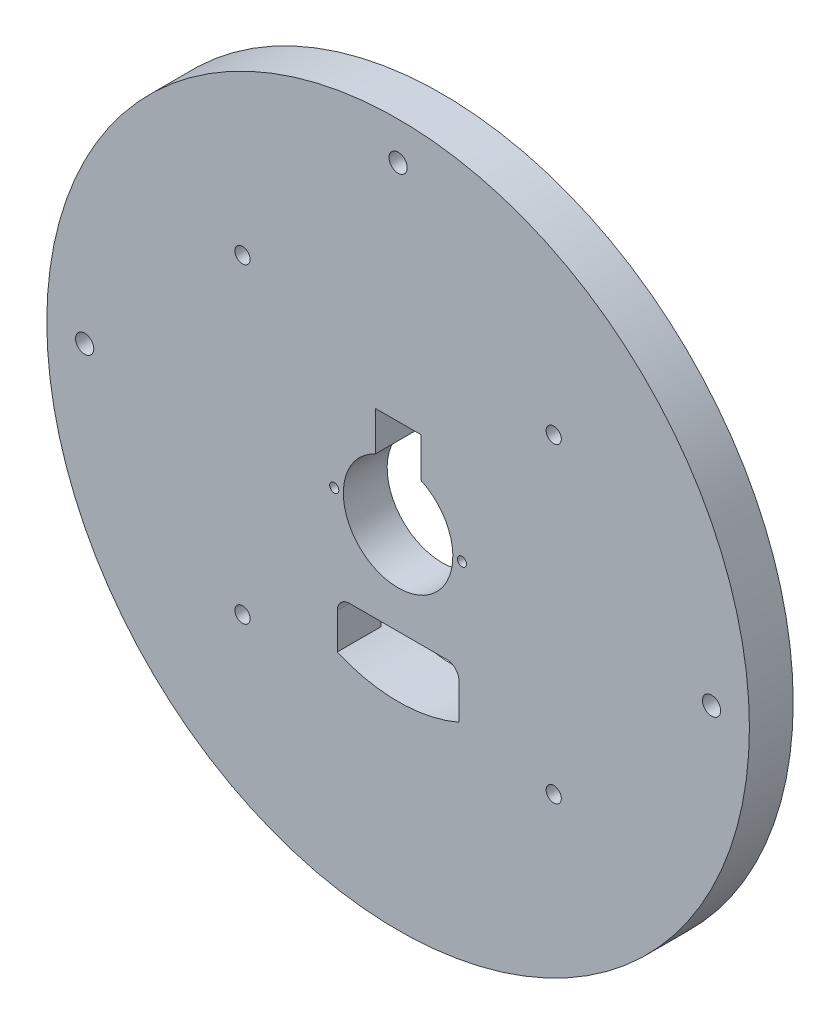
from build123d import *

# Parameters (mm, degrees)
BOSS_EXTRUDE1_DEPTH     = 14.4
MOTORMOUNTLOCKRINGS_R   = 90.6
MOTORMOUNTLOCKRINGS_R_2 = 50.4
BOSS_EXTRUDE2_DEPTH     = 5
CUT_EXTRUDE1_DEPTH      = 18.4
CUT_EXTRUDE2_DEPTH      = 15.4
F_5_0MM_DOWEL_HOLE1_D   = 5
F_3_0MM_DOWEL_HOLE3_D   = 3
F_6_0MM_DOWEL_HOLE4_D   = 6


with BuildPart() as part:
    # motorMount → Boss-Extrude1 (new body)
    with BuildSketch(Plane.XY):
        with BuildLine():
            ThreePointArc((115.302334192, 6.754385965), (0, 115.5), (-115.302334192, 6.754385965))
            ThreePointArc((-115.302334192, 6.754385965), (-115.5, 0), (-115.302334192, -6.754385965))
            ThreePointArc((-115.302334192, -6.754385965), (0, -115.5), (115.302334192, -6.754385965))
            ThreePointArc((115.302334192, -6.754385965), (115.5, 0), (115.302334192, 6.754385965))
        make_face()
    extrude(amount=BOSS_EXTRUDE1_DEPTH)

    # motorMountLockRings → Boss-Extrude2 (add)
    with BuildSketch(Plane(origin=(0, 0, 0), x_dir=(-1, 0, 0), z_dir=(0, 0, -1))):
        Circle(MOTORMOUNTLOCKRINGS_R)
        with BuildLine():
            Line((-55.16475324, 5.1), (-85.447937365, 5.1))
            ThreePointArc((-85.447937365, 5.1), (0, 85.6), (85.447937365, 5.1))
            Line((85.447937365, 5.1), (55.16475324, 5.1))
            ThreePointArc((55.16475324, 5.1), (0, 55.4), (-55.16475324, 5.1))
        make_face(mode=Mode.SUBTRACT)
        with BuildLine():
            ThreePointArc((85.447937365, -5.1), (0, -85.6), (-85.447937365, -5.1))
            Line((-85.447937365, -5.1), (-55.16475324, -5.1))
            ThreePointArc((-55.16475324, -5.1), (0, -55.4), (55.16475324, -5.1))
            Line((55.16475324, -5.1), (85.447937365, -5.1))
        make_face(mode=Mode.SUBTRACT)
        Circle(MOTORMOUNTLOCKRINGS_R_2, mode=Mode.SUBTRACT)
    extrude(amount=BOSS_EXTRUDE2_DEPTH)

    # motorMountMotorCavity → Cut-Extrude1 (cut)
    with BuildSketch(Plane(origin=(0, 0, 0), x_dir=(-1, 0, 0), z_dir=(0, 0, -1))):
        with BuildLine():
            Line((-7.5, 16.363068172), (-7.5, 29.363068172))
            Line((-7.5, 29.363068172), (7.5, 29.363068172))
            Line((7.5, 29.363068172), (7.5, 16.363068172))
            ThreePointArc((7.5, 16.363068172), (0, -18), (-7.5, 16.363068172))
        make_face()
    extrude(amount=-CUT_EXTRUDE1_DEPTH, mode=Mode.SUBTRACT)

    # motorMountPelletThroughHole → Cut-Extrude2 (cut, through all)
    with BuildSketch(Plane(origin=(0, 0, 0), x_dir=(-1, 0, 0), z_dir=(0, 0, -1))):
        with BuildLine():
            Line((-20, -46.261863343), (-20, -34.4))
            ThreePointArc((-20, -34.4), (-18.828427125, -31.571572875), (-16, -30.4))
            Line((-16, -30.4), (16, -30.4))
            ThreePointArc((16, -30.4), (18.828427125, -31.571572875), (20, -34.4))
            Line((20, -34.4), (20, -46.261863343))
            ThreePointArc((20, -46.261863343), (0, -50.4), (-20, -46.261863343))
        make_face()
    extrude(amount=-CUT_EXTRUDE2_DEPTH, mode=Mode.SUBTRACT)

    # Ø5.0mm Dowel Hole1 (through all)
    with Locations(Plane(origin=(0, 0, -16.7), x_dir=(-1, 0, 0), z_dir=(0, 0, -1))):
        with Locations((-51.159778753, -51.159778753), (51.159778753, -51.159778753), (51.159778753, 51.159778753), (-51.159778753, 51.159778753)):
            Hole(F_5_0MM_DOWEL_HOLE1_D / 2)

    # Ø3.0mm Dowel Hole3 (through all)
    with Locations(Plane(origin=(0, 0, 0), x_dir=(-1, 0, 0), z_dir=(0, 0, -1))):
        with Locations((-21, 0), (21, 0)):
            Hole(F_3_0MM_DOWEL_HOLE3_D / 2)

    # Ø6.0mm Dowel Hole4 (through all)
    with Locations(Plane.XY.offset(24.4)):
        with Locations((-103.05, 0), (103.05, 0), (0, 103.05)):
            Hole(F_6_0MM_DOWEL_HOLE4_D / 2)


solid = part.part
